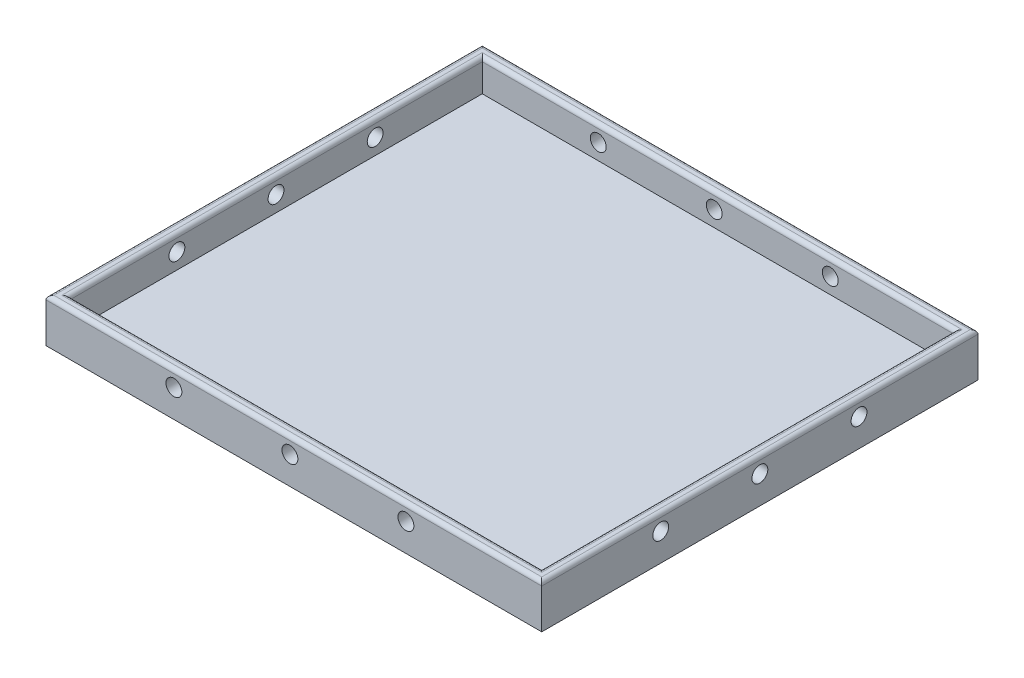
from build123d import *

# Parameters (mm, degrees)
SKETCH1_W               = 125
SKETCH1_H               = 110
BOSS_EXTRUDE1_DEPTH     = 11
SKETCH4_W               = 119
SKETCH4_H               = 104
CUT_EXTRUDE1_DEPTH      = 8
SKETCH6_R               = 2
CUT_EXTRUDE6_DEPTH      = 123
CUT_EXTRUDE6_DEPTH_BACK = 4
SKETCH5_R               = 2
CUT_EXTRUDE5_DEPTH      = 108
CUT_EXTRUDE5_DEPTH_BACK = 4
FILLET2_R               = 1


with BuildPart() as part:
    # Sketch1 → Boss-Extrude1 (new body)
    with BuildSketch(Plane(origin=(0, 0, 0), x_dir=(1, 0, 0), z_dir=(0, 1, 0))):
        with Locations((-139.109907121, 22.894736842)):
            Rectangle(SKETCH1_W, SKETCH1_H)
    extrude(amount=BOSS_EXTRUDE1_DEPTH)

    # Sketch4 → Cut-Extrude1 (cut)
    with BuildSketch(Plane(origin=(0, 11, 0), x_dir=(1, 0, 0), z_dir=(0, 1, 0))):
        with Locations((-139.109907121, 22.894736842)):
            Rectangle(SKETCH4_W, SKETCH4_H)
    extrude(amount=-CUT_EXTRUDE1_DEPTH, mode=Mode.SUBTRACT)

    # Sketch6 → Cut-Extrude6 (cut, two sides)
    with BuildSketch(Plane(origin=(-198.609907121, 0, 0), x_dir=(0, 0, -1), z_dir=(1, 0, 0))) as cut_extrude6_sk:
        with Locations((-2.105263158, 6.999999953)):
            Circle(SKETCH6_R)
        with Locations((22.894736842, 6.999999953)):
            Circle(SKETCH6_R)
        with Locations((47.894736842, 7)):
            Circle(SKETCH6_R)
    extrude(amount=CUT_EXTRUDE6_DEPTH, mode=Mode.SUBTRACT)
    extrude(cut_extrude6_sk.sketch, amount=-CUT_EXTRUDE6_DEPTH_BACK, mode=Mode.SUBTRACT)

    # Sketch5 → Cut-Extrude5 (cut, two sides)
    with BuildSketch(Plane.XY.offset(-74.894736842)) as cut_extrude5_sk:
        with Locations((-169.359907121, 7)):
            Circle(SKETCH5_R)
        with Locations((-140.109907121, 7)):
            Circle(SKETCH5_R)
        with Locations((-110.859907121, 7)):
            Circle(SKETCH5_R)
    extrude(amount=CUT_EXTRUDE5_DEPTH, mode=Mode.SUBTRACT)
    extrude(cut_extrude5_sk.sketch, amount=-CUT_EXTRUDE5_DEPTH_BACK, mode=Mode.SUBTRACT)

    # Fillet2
    fillet2_edges = [part.edges().sort_by_distance(p)[0] for p in [
        (-76.609907121, 11, -22.894736842),
        (-139.109907121, 11, -77.894736842),
        (-198.609907121, 11, -22.894736842),
        (-139.109907121, 11, 29.105263158),
        (-79.609907121, 11, -22.894736842),
        (-139.109907121, 11, -74.894736842),
        (-201.609907121, 11, -22.894736842),
        (-139.109907121, 11, 32.105263158),
    ]]
    fillet(fillet2_edges, radius=FILLET2_R)


solid = part.part
